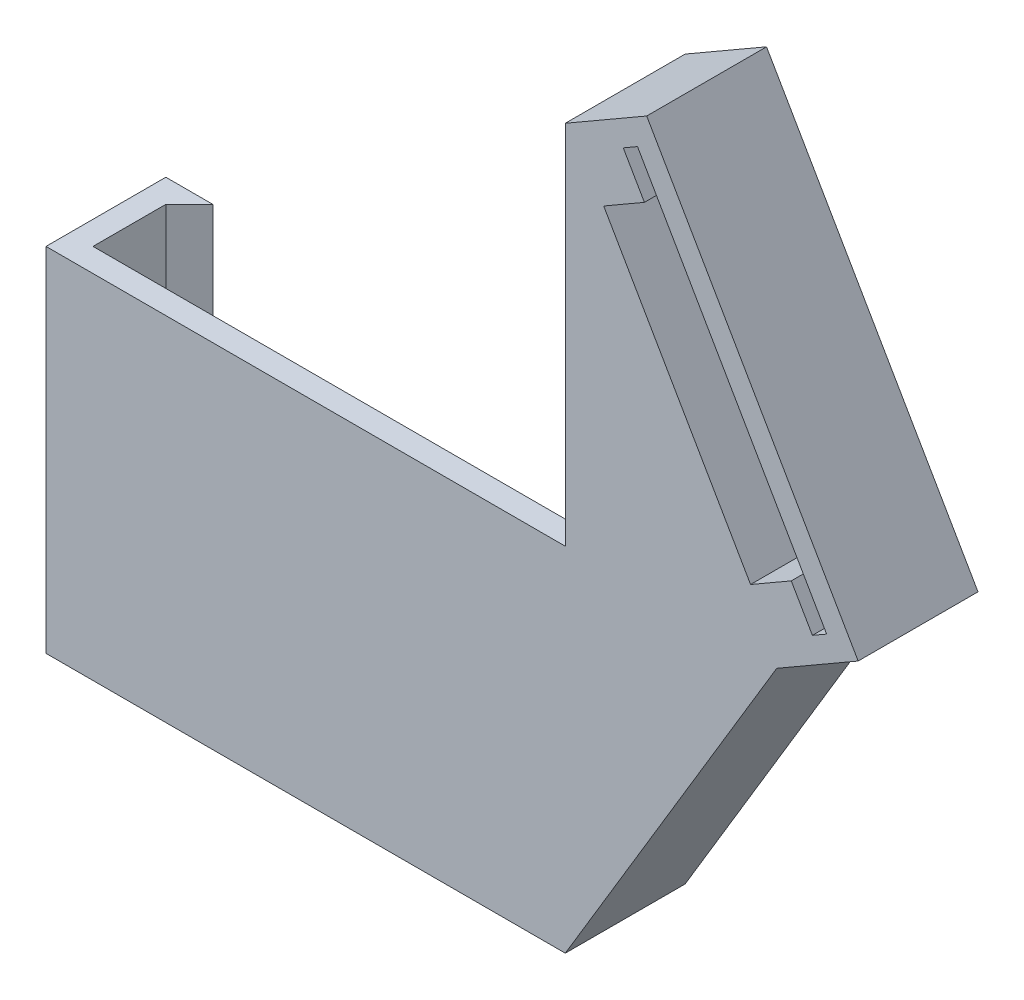
from build123d import *

# Parameters (mm, degrees)
BOSS_EXTRUDE1_DEPTH = 30
BOSS_EXTRUDE2_DEPTH = 10.2
CUT_EXTRUDE1_DEPTH  = 10.2


with BuildPart() as part:
    # Sketch1 → Boss-Extrude1 (new body)
    with BuildSketch(Plane(origin=(0, 0, 0), x_dir=(1, 0, 0), z_dir=(0, 1, 0))):
        Polygon((18.1, 3.1), (18.1, 5.1), (22.1, 5.1), (22.1, -5.1), (-22.1, -5.1), (-22.1, 5.1), (-18.1, 5.1), (-20.1, 3.1), (-20.1, -3.1), (20.1, -3.1), (20.1, 3.1), align=None)
    extrude(amount=BOSS_EXTRUDE1_DEPTH)

    # Sketch2 → Boss-Extrude2 (add)
    with BuildSketch(Plane.XY.offset(5.1)):
        Polygon((47.02820323, 34), (29.02820323, 65.176914536), (22.1, 61.176914536), (22.1, 30), (22.1, 0), (40.1, 30), align=None)
    extrude(amount=-BOSS_EXTRUDE2_DEPTH)

    # Sketch3 → Cut-Extrude1 (cut)
    with BuildSketch(Plane.XY.offset(5.1)):
        Polygon((44.346152423, 34.645448267), (28.246152423, 62.531466269), (27.033716857, 61.831466269), (28.833716857, 58.713774815), (25.369615242, 56.713774815), (37.869615242, 35.063139721), (41.333716857, 37.063139721), (43.133716857, 33.945448267), align=None)
    extrude(amount=-CUT_EXTRUDE1_DEPTH, mode=Mode.SUBTRACT)


solid = part.part
